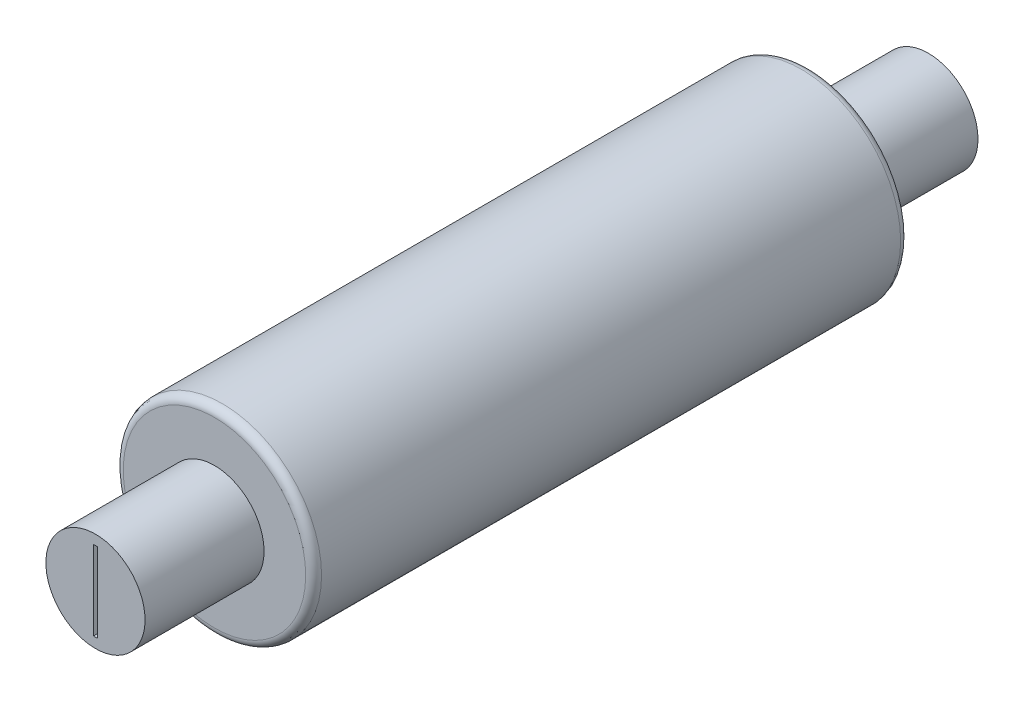
from build123d import *

# Parameters (mm, degrees)
SKETCH1_R           = 25
BOSS_EXTRUDE2_DEPTH = 75
SKETCH2_R           = 12.5
SKETCH2_W           = 1
SKETCH2_H           = 20
BOSS_EXTRUDE3_DEPTH = 30
FILLET2_R           = 2


with BuildPart() as part:
    # Sketch1 → Boss-Extrude2 (new body, symmetric)
    with BuildSketch(Plane.XY):
        Circle(SKETCH1_R)
    extrude(amount=BOSS_EXTRUDE2_DEPTH, both=True)

    # Sketch2 → Boss-Extrude3 (add)
    with BuildSketch(Plane.XY.offset(75)):
        Circle(SKETCH2_R)
        Rectangle(SKETCH2_W, SKETCH2_H, mode=Mode.SUBTRACT)
    boss_extrude3 = extrude(amount=BOSS_EXTRUDE3_DEPTH)

    # Mirror1: Boss-Extrude3 across plane
    add(boss_extrude3.mirror(Plane.XY))

    # Fillet2
    fillet2_edges = [part.edges().sort_by_distance(p)[0] for p in [
        (-25, 0, -75),
        (-25, 0, 75),
    ]]
    fillet(fillet2_edges, radius=FILLET2_R)


solid = part.part
